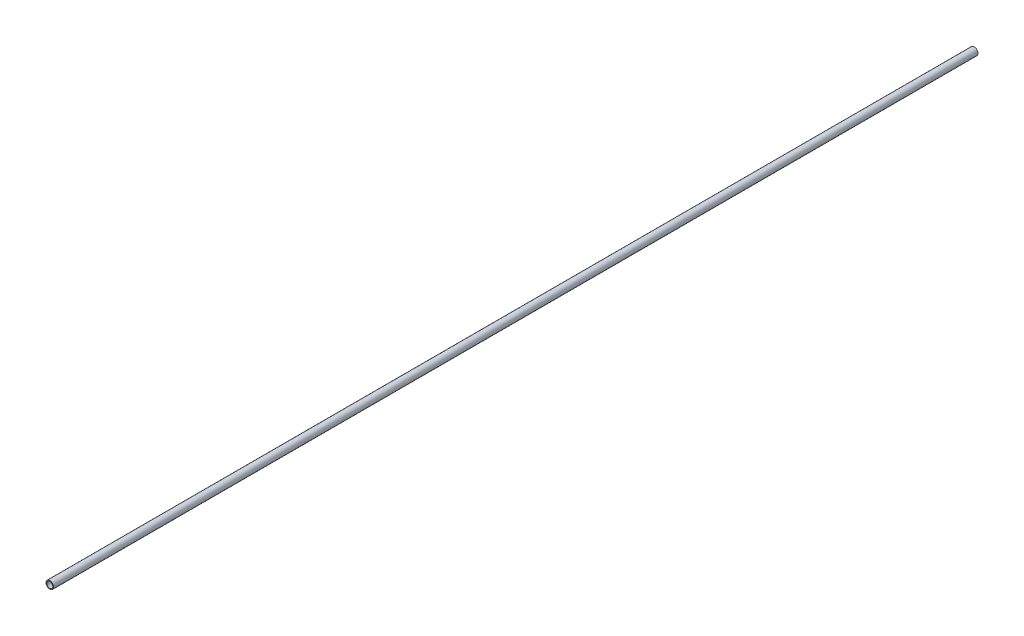
from build123d import *

# Parameters (mm, degrees)
SKETCH_1_R      = 2.5
SKETCH_1_R_2    = 2
EXTRUDE_1_DEPTH = 610


with BuildPart() as part:
    # ｽｹｯﾁ1 → ﾎﾞｽ - 押し出し1 (new body)
    with BuildSketch(Plane.XY):
        Circle(SKETCH_1_R)
        Circle(SKETCH_1_R_2, mode=Mode.SUBTRACT)
    extrude(amount=EXTRUDE_1_DEPTH)


solid = part.part
